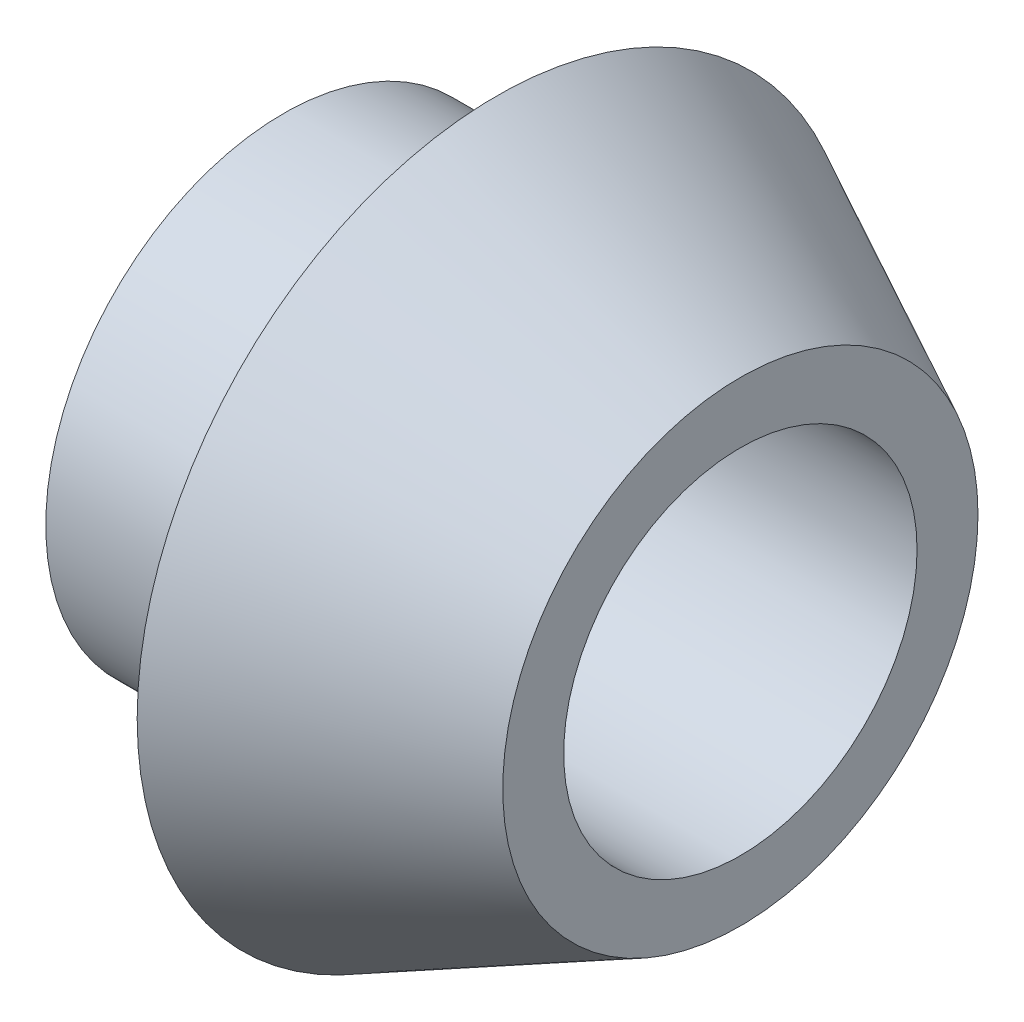
from build123d import *


with BuildPart() as part:
    # Sketch1 → Revolve2 (revolve)
    with BuildSketch(Plane.XY):
        Polygon((0, 0), (7.5, 0), (7.5, 1), (3.5, 3), (3.5, 1), (0, 1), align=None)
    revolve(axis=Axis((7.5, -2.9, 0), (-1, 0, 0)))


solid = part.part
